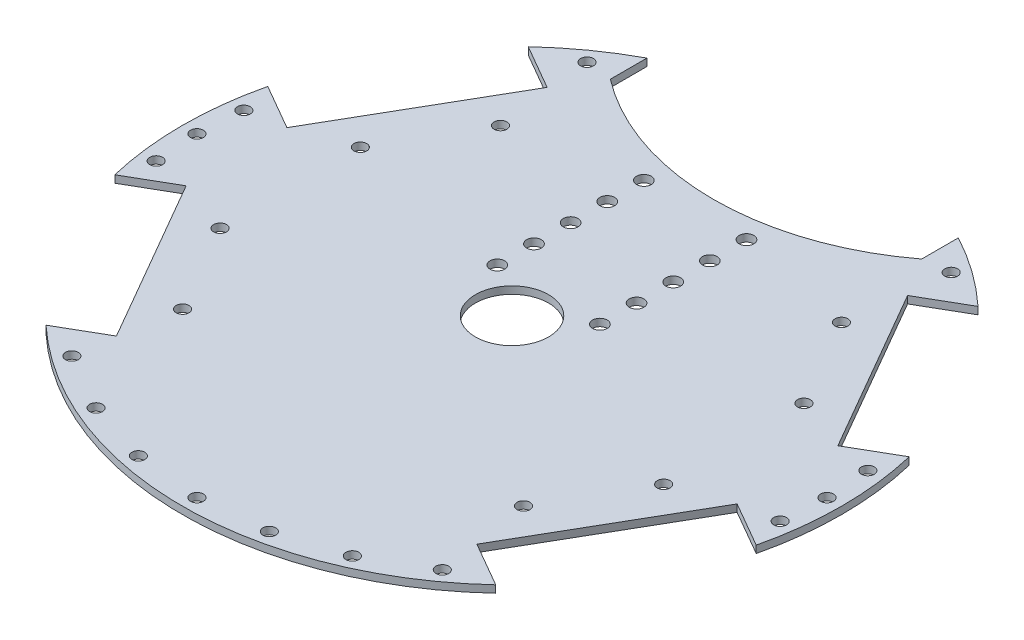
from build123d import *

# Parameters (mm, degrees)
SKETCH1_R                       = 90
BOSS_EXTRUDE1_DEPTH             = 2
CUT_EXTRUDE1_DEPTH              = 3
SKETCH5_R                       = 1.75
CUT_EXTRUDE3_DEPTH              = 3
MIRROR2_COPY_1_DEPTH            = 3
MIRROR2_COPY_2_SKETCH_R         = 1.75
MIRROR2_COPY_2_DEPTH            = 3
CUT_EXTRUDE2_DEPTH              = 3
SKETCH6_R                       = 10
CUT_EXTRUDE4_DEPTH              = 3
SKETCH7_R                       = 1.75
CUT_EXTRUDE5_DEPTH              = 3
CIRPATTERN1_COUNT               = 4
CIRPATTERN1_ANGLE               = 36
CIRPATTERN1_THE_OTHER_WAY_COUNT = 4
CIRPATTERN1_THE_OTHER_WAY_ANGLE = 36
SKETCH8_R                       = 1.75
CUT_EXTRUDE6_DEPTH              = 3
SKETCH9_R                       = 1.75
CUT_EXTRUDE7_DEPTH              = 3
CIRPATTERN2_COUNT               = 2
CIRPATTERN2_ANGLE               = 8
CIRPATTERN2_THE_OTHER_WAY_COUNT = 2
CIRPATTERN2_THE_OTHER_WAY_ANGLE = 8
MIRROR3_COPY_1_SKETCH_R         = 1.75
MIRROR3_COPY_1_DEPTH            = 3
MIRROR3_COPY_2_SKETCH_R         = 1.75
MIRROR3_COPY_2_DEPTH            = 3
SKETCH10_R                      = 2
CUT_EXTRUDE8_DEPTH              = 3
LPATTERN1_COUNT                 = 5
LPATTERN1_PITCH                 = 10
LPATTERN1_COPY_1_SKETCH_R       = 2
LPATTERN1_COPY_1_DEPTH          = 3
LPATTERN1_COPY_2_SKETCH_R       = 2
LPATTERN1_COPY_2_DEPTH          = 3
LPATTERN1_COPY_3_SKETCH_R       = 2
LPATTERN1_COPY_3_DEPTH          = 3
LPATTERN1_COPY_4_SKETCH_R       = 2
LPATTERN1_COPY_4_DEPTH          = 3


with BuildPart() as part:
    # Sketch1 → Boss-Extrude1 (new body)
    with BuildSketch(Plane(origin=(0, 0, 0), x_dir=(1, 0, 0), z_dir=(0, 1, 0))):
        Circle(SKETCH1_R)
    extrude(amount=BOSS_EXTRUDE1_DEPTH)

    # Sketch3 → Cut-Extrude1 (cut, through all)
    with BuildSketch(Plane(origin=(0, 2, 0), x_dir=(1, 0, 0), z_dir=(0, 1, 0))):
        Polygon((-106.374227687, 31.753350771), (-80.374227687, 76.786671768), (-49.197313151, 58.786671768), (-75.197313151, 13.753350771), align=None)
    cut_extrude1 = extrude(amount=-CUT_EXTRUDE1_DEPTH, mode=Mode.SUBTRACT)

    # Sketch5 → Cut-Extrude3 (cut, through all)
    with BuildSketch(Plane(origin=(0, 2, 0), x_dir=(1, 0, 0), z_dir=(0, 1, 0))):
        with Locations((-60.537059113, 19.145655616)):
            Circle(SKETCH5_R)
        with Locations((-46.537059113, 43.394366922)):
            Circle(SKETCH5_R)
    cut_extrude3 = extrude(amount=-CUT_EXTRUDE3_DEPTH, mode=Mode.SUBTRACT)

    # Mirror1: Cut-Extrude1, Cut-Extrude3 across plane
    add(cut_extrude1.mirror(Plane.XY), mode=Mode.SUBTRACT)
    add(cut_extrude3.mirror(Plane.XY), mode=Mode.SUBTRACT)

    # Mirror2: Cut-Extrude1, Cut-Extrude3 across plane
    add(cut_extrude1.mirror(Plane(origin=(0, 0, 0), x_dir=(0, 0, 1), z_dir=(1, 0, 0))), mode=Mode.SUBTRACT)
    add(cut_extrude3.mirror(Plane(origin=(0, 0, 0), x_dir=(0, 0, 1), z_dir=(1, 0, 0))), mode=Mode.SUBTRACT)

    # Mirror2 copy 1 sketch → Mirror2 copy 1 (cut, through all)
    with BuildSketch(Plane(origin=(0, 2, 0), x_dir=(-1, 0, 0), z_dir=(0, 1, 0))):
        Polygon((-106.374227687, 31.753350771), (-80.374227687, 76.786671768), (-49.197313151, 58.786671768), (-75.197313151, 13.753350771), align=None)
    extrude(amount=-MIRROR2_COPY_1_DEPTH, mode=Mode.SUBTRACT)

    # Mirror2 copy 2 sketch → Mirror2 copy 2 (cut, through all)
    with BuildSketch(Plane(origin=(0, 2, 0), x_dir=(-1, 0, 0), z_dir=(0, 1, 0))):
        with Locations((-60.537059113, 19.145655616)):
            Circle(MIRROR2_COPY_2_SKETCH_R)
        with Locations((-46.537059113, 43.394366922)):
            Circle(MIRROR2_COPY_2_SKETCH_R)
    extrude(amount=-MIRROR2_COPY_2_DEPTH, mode=Mode.SUBTRACT)

    # Sketch4 → Cut-Extrude2 (cut, through all)
    with BuildSketch(Plane(origin=(0, 2, 0), x_dir=(1, 0, 0), z_dir=(0, 1, 0))):
        with BuildLine():
            Line((-42.5, 79.333158263), (-42.5, 69.333158263))
            ThreePointArc((-42.5, 69.333158263), (0, 55), (42.5, 69.333158263))
            Line((42.5, 69.333158263), (42.5, 79.333158263))
            Line((42.5, 79.333158263), (42.5, 105.809765059))
            Line((42.5, 105.809765059), (-42.5, 105.809765059))
            Line((-42.5, 105.809765059), (-42.5, 79.333158263))
        make_face()
    extrude(amount=-CUT_EXTRUDE2_DEPTH, mode=Mode.SUBTRACT)

    # Sketch6 → Cut-Extrude4 (cut, through all)
    with BuildSketch(Plane(origin=(0, 2, 0), x_dir=(1, 0, 0), z_dir=(0, 1, 0))):
        Circle(SKETCH6_R)
    extrude(amount=-CUT_EXTRUDE4_DEPTH, mode=Mode.SUBTRACT)

    # Sketch7 → Cut-Extrude5 (cut, through all)
    with BuildSketch(Plane.XZ):
        with Locations((0, 86)):
            Circle(SKETCH7_R)
    cut_extrude5 = extrude(amount=-CUT_EXTRUDE5_DEPTH, mode=Mode.SUBTRACT)

    # CirPattern1: Cut-Extrude5 ×4 about axis
    cirpattern1_axis = Axis((0, 0, 0), (0, 1, 0))
    for i in range(1, CIRPATTERN1_COUNT):
        add(cut_extrude5.rotate(cirpattern1_axis, i * CIRPATTERN1_ANGLE / (CIRPATTERN1_COUNT - 1)), mode=Mode.SUBTRACT)

    # CirPattern1 the other way: Cut-Extrude5 ×4 about axis
    cirpattern1_the_other_way_axis = Axis((0, 0, 0), (0, -1, 0))
    for i in range(1, CIRPATTERN1_THE_OTHER_WAY_COUNT):
        add(cut_extrude5.rotate(cirpattern1_the_other_way_axis, i * CIRPATTERN1_THE_OTHER_WAY_ANGLE / (CIRPATTERN1_THE_OTHER_WAY_COUNT - 1)), mode=Mode.SUBTRACT)

    # Sketch8 → Cut-Extrude6 (cut, through all)
    with BuildSketch(Plane(origin=(0, 2, 0), x_dir=(1, 0, 0), z_dir=(0, 1, 0))):
        with Locations((-86, 0)):
            Circle(SKETCH8_R)
    cut_extrude6 = extrude(amount=-CUT_EXTRUDE6_DEPTH, mode=Mode.SUBTRACT)

    # Sketch9 → Cut-Extrude7 (cut, through all)
    with BuildSketch(Plane(origin=(0, 2, 0), x_dir=(1, 0, 0), z_dir=(0, 1, 0))):
        with Locations((-49.706440821, 70.180266036)):
            Circle(SKETCH9_R)
    cut_extrude7 = extrude(amount=-CUT_EXTRUDE7_DEPTH, mode=Mode.SUBTRACT)

    # CirPattern2: Cut-Extrude6 ×2 about axis
    cirpattern2_axis = Axis((0, 2, 0), (0, 1, 0))
    for i in range(1, CIRPATTERN2_COUNT):
        add(cut_extrude6.rotate(cirpattern2_axis, i * CIRPATTERN2_ANGLE / (CIRPATTERN2_COUNT - 1)), mode=Mode.SUBTRACT)

    # CirPattern2 the other way: Cut-Extrude6 ×2 about axis
    cirpattern2_the_other_way_axis = Axis((0, 2, 0), (0, -1, 0))
    for i in range(1, CIRPATTERN2_THE_OTHER_WAY_COUNT):
        add(cut_extrude6.rotate(cirpattern2_the_other_way_axis, i * CIRPATTERN2_THE_OTHER_WAY_ANGLE / (CIRPATTERN2_THE_OTHER_WAY_COUNT - 1)), mode=Mode.SUBTRACT)

    # Mirror3: Cut-Extrude7, Cut-Extrude6 across plane
    add(cut_extrude7.mirror(Plane(origin=(0, 0, 0), x_dir=(0, 0, 1), z_dir=(1, 0, 0))), mode=Mode.SUBTRACT)
    add(cut_extrude6.mirror(Plane(origin=(0, 0, 0), x_dir=(0, 0, 1), z_dir=(1, 0, 0))), mode=Mode.SUBTRACT)

    # Mirror3 copy 1 sketch → Mirror3 copy 1 (cut, through all)
    with BuildSketch(Plane(origin=(0, 2, 0), x_dir=(-0.990268069, 0, -0.139173101), z_dir=(0, 1, 0))):
        with Locations((-86, 0)):
            Circle(MIRROR3_COPY_1_SKETCH_R)
    extrude(amount=-MIRROR3_COPY_1_DEPTH, mode=Mode.SUBTRACT)

    # Mirror3 copy 2 sketch → Mirror3 copy 2 (cut, through all)
    with BuildSketch(Plane(origin=(0, 2, 0), x_dir=(-0.990268069, 0, 0.139173101), z_dir=(0, 1, 0))):
        with Locations((-86, 0)):
            Circle(MIRROR3_COPY_2_SKETCH_R)
    extrude(amount=-MIRROR3_COPY_2_DEPTH, mode=Mode.SUBTRACT)

    # Sketch10 → Cut-Extrude8 (cut, through all)
    with BuildSketch(Plane(origin=(0, 2, 0), x_dir=(1, 0, 0), z_dir=(0, 1, 0))):
        with Locations((14, 50)):
            Circle(SKETCH10_R)
    cut_extrude8 = extrude(amount=-CUT_EXTRUDE8_DEPTH, mode=Mode.SUBTRACT)

    # Mirror4: Cut-Extrude8 across plane
    add(cut_extrude8.mirror(Plane(origin=(0, 0, 0), x_dir=(0, 0, 1), z_dir=(1, 0, 0))), mode=Mode.SUBTRACT)

    # LPattern1: Cut-Extrude8 ×5
    with Locations(*[(0, 0, i * LPATTERN1_PITCH) for i in range(1, LPATTERN1_COUNT)]):
        add(cut_extrude8, mode=Mode.SUBTRACT)

    # LPattern1 copy 1 sketch → LPattern1 copy 1 (cut, through all)
    with BuildSketch(Plane(origin=(0, 2, 10), x_dir=(-1, 0, 0), z_dir=(0, 1, 0))):
        with Locations((14, -50)):
            Circle(LPATTERN1_COPY_1_SKETCH_R)
    extrude(amount=-LPATTERN1_COPY_1_DEPTH, mode=Mode.SUBTRACT)

    # LPattern1 copy 2 sketch → LPattern1 copy 2 (cut, through all)
    with BuildSketch(Plane(origin=(0, 2, 20), x_dir=(-1, 0, 0), z_dir=(0, 1, 0))):
        with Locations((14, -50)):
            Circle(LPATTERN1_COPY_2_SKETCH_R)
    extrude(amount=-LPATTERN1_COPY_2_DEPTH, mode=Mode.SUBTRACT)

    # LPattern1 copy 3 sketch → LPattern1 copy 3 (cut, through all)
    with BuildSketch(Plane(origin=(0, 2, 30), x_dir=(-1, 0, 0), z_dir=(0, 1, 0))):
        with Locations((14, -50)):
            Circle(LPATTERN1_COPY_3_SKETCH_R)
    extrude(amount=-LPATTERN1_COPY_3_DEPTH, mode=Mode.SUBTRACT)

    # LPattern1 copy 4 sketch → LPattern1 copy 4 (cut, through all)
    with BuildSketch(Plane(origin=(0, 2, 40), x_dir=(-1, 0, 0), z_dir=(0, 1, 0))):
        with Locations((14, -50)):
            Circle(LPATTERN1_COPY_4_SKETCH_R)
    extrude(amount=-LPATTERN1_COPY_4_DEPTH, mode=Mode.SUBTRACT)


solid = part.part
